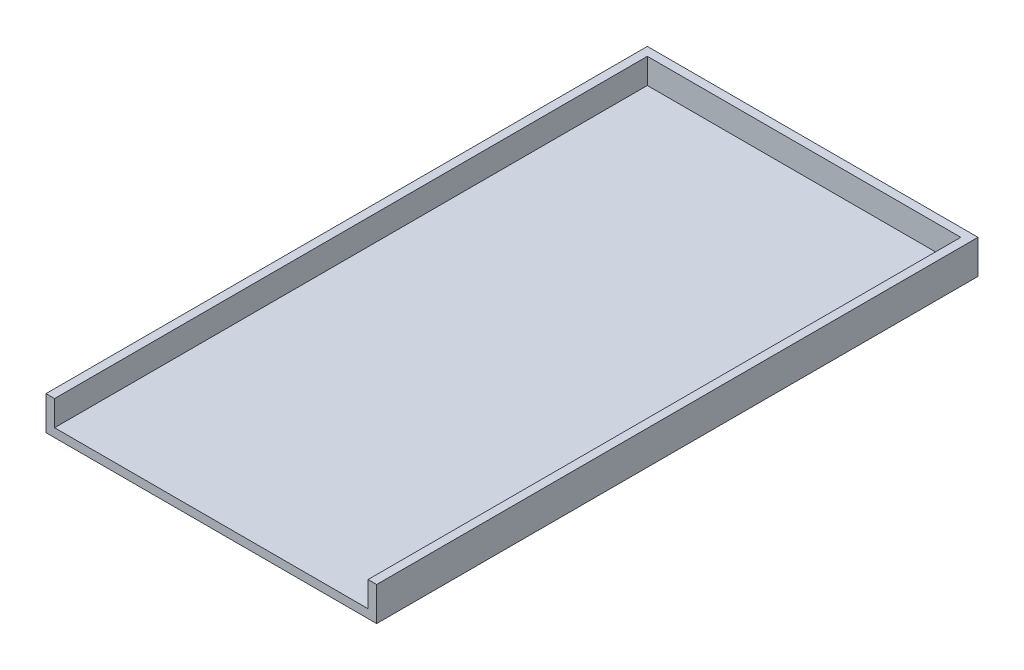
from build123d import *

# Parameters (mm, degrees)
SKETCH2_W           = 122.201758268
SKETCH2_H           = 12.52058784
BOSS_EXTRUDE1_DEPTH = 222.25
SHELL1_T            = -3.175


with BuildPart() as part:
    # Sketch2 → Boss-Extrude1 (new body)
    with BuildSketch(Plane.XY):
        with Locations((-24.147384347, -59.653504879)):
            Rectangle(SKETCH2_W, SKETCH2_H)
    extrude(amount=BOSS_EXTRUDE1_DEPTH)

    # Shell1
    shell1_openings = [part.faces().sort_by_distance(p)[0] for p in [
        (-24.147384347, -59.653504879, 222.25),
        (-24.147384347, -53.393210959, 111.125),
    ]]
    offset(amount=SHELL1_T, openings=shell1_openings, kind=Kind.INTERSECTION)


solid = part.part
